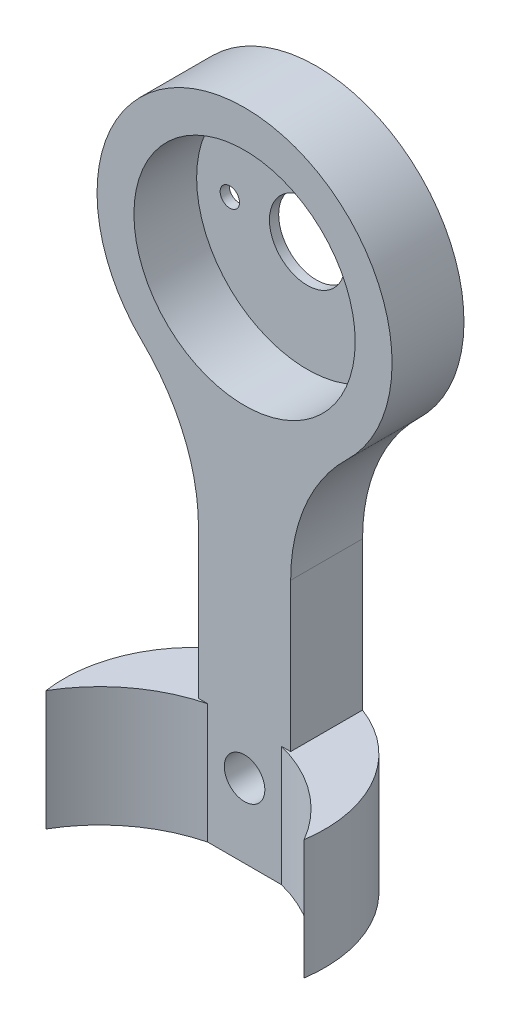
from build123d import *

# Parameters (mm, degrees)
SKETCH1_R           = 6
SKETCH1_R_2         = 1.1
BOSS_EXTRUDE1_DEPTH = 3.9
SKETCH5_R           = 8
SKETCH5_R_2         = 2.05
SKETCH5_R_3         = 0.525
BOSS_EXTRUDE3_DEPTH = 0.5
BOSS_EXTRUDE4_DEPTH = 6.5


with BuildPart() as part:
    # Sketch1 → Boss-Extrude1 (new body)
    with BuildSketch(Plane.XY):
        with BuildLine():
            Line((-2.5, -27.5), (2.5, -27.5))
            Line((2.5, -27.5), (2.5, -12.951833847))
            ThreePointArc((2.5, -12.951833847), (3.295532486, -9.043154047), (5.555555556, -5.756370599))
            ThreePointArc((5.555555556, -5.756370599), (0, 8), (-5.555555556, -5.756370599))
            ThreePointArc((-5.555555556, -5.756370599), (-3.295532486, -9.043154047), (-2.5, -12.951833847))
            Line((-2.5, -12.951833847), (-2.5, -27.5))
        make_face()
        Circle(SKETCH1_R, mode=Mode.SUBTRACT)
        with Locations((0, -23.5)):
            Circle(SKETCH1_R_2, mode=Mode.SUBTRACT)
    extrude(amount=BOSS_EXTRUDE1_DEPTH)

    # Sketch5 → Boss-Extrude3 (add)
    with BuildSketch(Plane(origin=(0, 0, 0), x_dir=(-1, 0, 0), z_dir=(0, 0, -1))):
        Circle(SKETCH5_R)
        Circle(SKETCH5_R_2, mode=Mode.SUBTRACT)
        with Locations((4.2, 0)):
            Circle(SKETCH5_R_3, mode=Mode.SUBTRACT)
        with Locations((-4.2, 0)):
            Circle(SKETCH5_R_3, mode=Mode.SUBTRACT)
    extrude(amount=-BOSS_EXTRUDE3_DEPTH)

    # Sketch7 → Boss-Extrude4 (add)
    with BuildSketch(Plane.XZ.offset(27.5)):
        with BuildLine():
            ThreePointArc((7, 7.666888651), (4.877255668, 5.281037947), (1.997835367, 3.9))
            Line((1.997835367, 3.9), (2.5, 3.9))
            Line((2.5, 3.9), (2.5, 0))
            ThreePointArc((2.5, 0), (6.103916398, 3.038777275), (7, 7.666888651))
        make_face()
        with BuildLine():
            Line((-2.5, 3.9), (-1.997835367, 3.9))
            ThreePointArc((-1.997835367, 3.9), (-4.877255668, 5.281037947), (-7, 7.666888651))
            ThreePointArc((-7, 7.666888651), (-6.103916398, 3.038777275), (-2.5, 0))
            Line((-2.5, 0), (-2.5, 3.9))
        make_face()
    extrude(amount=-BOSS_EXTRUDE4_DEPTH)


solid = part.part
